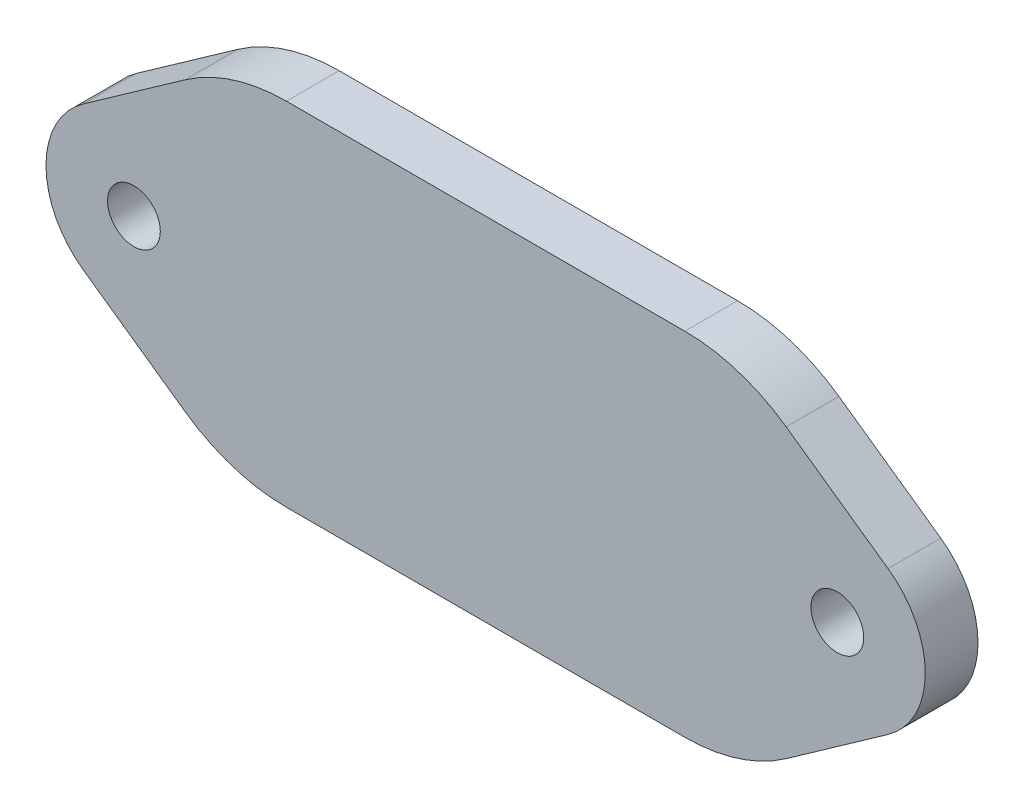
from build123d import *

# Parameters (mm, degrees)
ESBO_O1_R                = 1.5
ESBO_O1_W                = 29
ESBO_O1_H                = 20
RESSALTO_EXTRUS_O1_DEPTH = 3
FILETE1_R                = 10


with BuildPart() as part:
    # Esboço1 → Ressalto-extrusão1 (new body)
    with BuildSketch(Plane.XY):
        with BuildLine():
            Line((-22.882588201, 4.085423511), (-14.5, 10))
            Line((-14.5, 10), (-14.5, -10))
            Line((-14.5, -10), (-22.882588201, -4.085423511))
            ThreePointArc((-22.882588201, -4.085423511), (-25, 0), (-22.882588201, 4.085423511))
        make_face()
        with Locations((-20, 0)):
            Circle(ESBO_O1_R, mode=Mode.SUBTRACT)
        Rectangle(ESBO_O1_W, ESBO_O1_H)
        with BuildLine():
            ThreePointArc((22.882588201, 4.085423511), (25, 0), (22.882588201, -4.085423511))
            Line((22.882588201, -4.085423511), (14.5, -10))
            Line((14.5, -10), (14.5, 10))
            Line((14.5, 10), (22.882588201, 4.085423511))
        make_face()
        with Locations((20, 0)):
            Circle(ESBO_O1_R, mode=Mode.SUBTRACT)
    extrude(amount=RESSALTO_EXTRUS_O1_DEPTH)

    # Filete1
    filete1_edges = [part.edges().sort_by_distance(p)[0] for p in [
        (-14.5, 10, 1.5),
        (14.5, 10, 1.5),
        (14.5, -10, 1.5),
        (-14.5, -10, 1.5),
    ]]
    fillet(filete1_edges, radius=FILETE1_R)


solid = part.part
